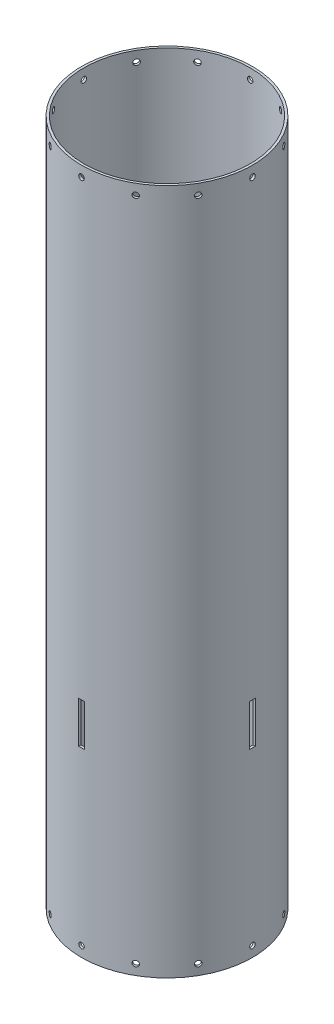
from build123d import *

# Parameters (mm, degrees)
SKETCH1_R           = 78.359
SKETCH1_R_2         = 76.2
BOSS_EXTRUDE1_DEPTH = 628.65
SKETCH2_R           = 2.54
CUT_EXTRUDE1_DEPTH  = 639.342453752
CIRPATTERN1_COUNT   = 12
SKETCH3_W           = 5.08
SKETCH3_H           = 38.1
CUT_EXTRUDE2_DEPTH  = 639.342453877
CIRPATTERN2_COUNT   = 4


with BuildPart() as part:
    # Sketch1 → Boss-Extrude1 (new body)
    with BuildSketch(Plane(origin=(0, 0, 0), x_dir=(1, 0, 0), z_dir=(0, 1, 0))):
        Circle(SKETCH1_R)
        Circle(SKETCH1_R_2, mode=Mode.SUBTRACT)
    extrude(amount=BOSS_EXTRUDE1_DEPTH)

    # Sketch2 → Cut-Extrude1 (cut, through all)
    with BuildSketch(Plane.XY):
        with Locations((0, 9.525)):
            Circle(SKETCH2_R)
        with Locations((0, 619.125)):
            Circle(SKETCH2_R)
    cut_extrude1 = extrude(amount=-CUT_EXTRUDE1_DEPTH, mode=Mode.SUBTRACT)

    # CirPattern1: Cut-Extrude1 ×12 about axis
    cirpattern1_axis = Axis((0, 0, 0), (0, 1, 0))
    for i in range(1, CIRPATTERN1_COUNT):
        add(cut_extrude1.rotate(cirpattern1_axis, i * 360 / CIRPATTERN1_COUNT), mode=Mode.SUBTRACT)

    # Sketch3 → Cut-Extrude2 (cut, through all)
    with BuildSketch(Plane.XY):
        with Locations((0, 185.42)):
            Rectangle(SKETCH3_W, SKETCH3_H)
    cut_extrude2 = extrude(amount=-CUT_EXTRUDE2_DEPTH, mode=Mode.SUBTRACT)

    # CirPattern2: Cut-Extrude2 ×4 about axis
    cirpattern2_axis = Axis((0, 628.65, 0), (0, -1, 0))
    for i in range(1, CIRPATTERN2_COUNT):
        add(cut_extrude2.rotate(cirpattern2_axis, i * 360 / CIRPATTERN2_COUNT), mode=Mode.SUBTRACT)


solid = part.part
